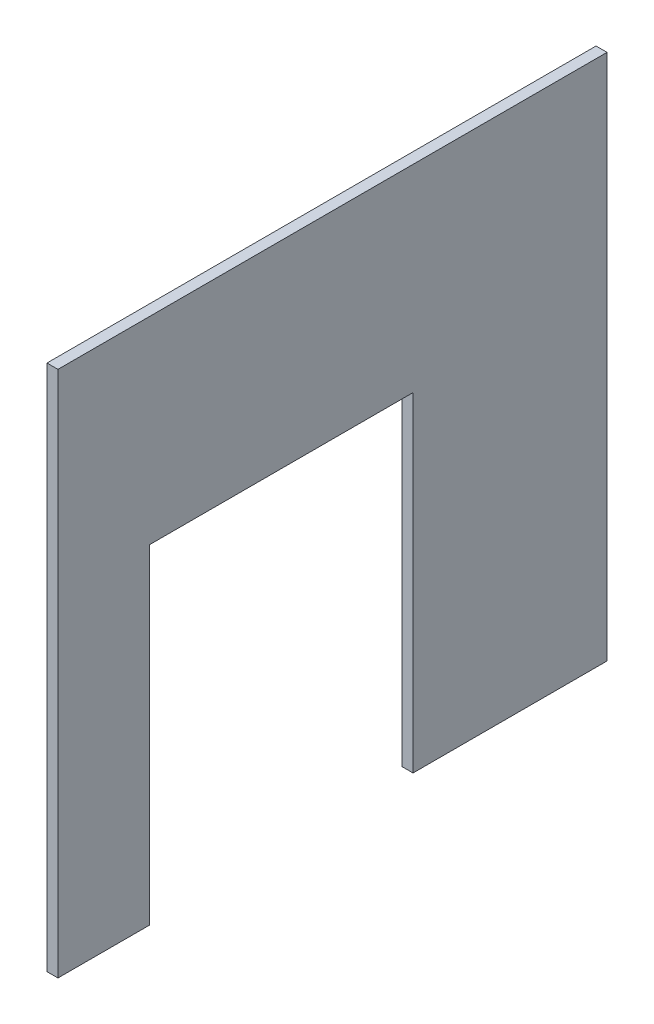
from build123d import *

# Parameters (mm, degrees)
BOSS_EXTRUDE1_DEPTH = 6


with BuildPart() as part:
    # Sketch1 → Boss-Extrude1 (new body)
    with BuildSketch(Plane(origin=(0, 0, 0), x_dir=(0, 0, -1), z_dir=(1, 0, 0))):
        Polygon((0, 0), (50, 0), (50, 180), (194, 180), (194, 0), (300, 0), (300, 288), (0, 288), align=None)
    extrude(amount=BOSS_EXTRUDE1_DEPTH)


solid = part.part
